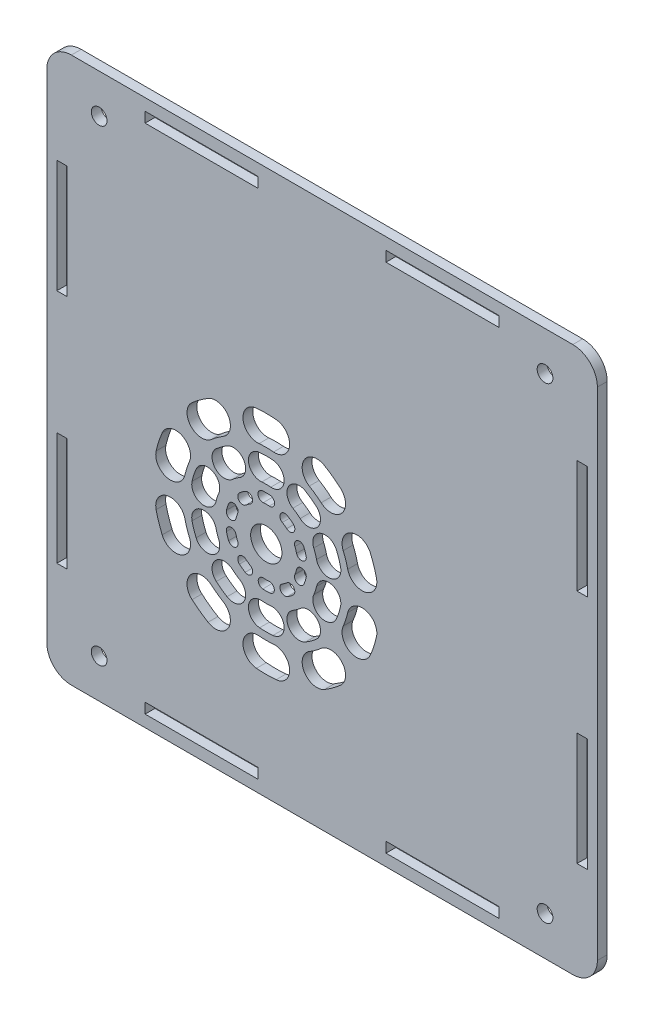
from build123d import *

# Parameters (mm, degrees)
SKETCH_1_W          = 112
SKETCH_1_H          = 111
EXTRUDE_1_DEPTH     = 2
SKETCH_2_R          = 1.6
CUT_EXTRUDE_1_DEPTH = 3
SKETCH_3_W          = 2.1
SKETCH_3_H          = 23
SKETCH_3_W_2        = 23
SKETCH_3_H_2        = 2.1
CUT_EXTRUDE_2_DEPTH = 3
SKETCH_4_R          = 3.180968653
CUT_EXTRUDE_4_DEPTH = 10
FILLET_1_R          = 5


with BuildPart() as part:
    # 草图1 → 凸台-拉伸1 (new body)
    with BuildSketch(Plane.XY):
        Rectangle(SKETCH_1_W, SKETCH_1_H)
    extrude(amount=EXTRUDE_1_DEPTH)

    # 草图2 → 切除-拉伸1 (cut, through all)
    with BuildSketch(Plane(origin=(0, 0, 0), x_dir=(-1, 0, 0), z_dir=(0, 0, -1))):
        with Locations((-45.35, -47.55)):
            Circle(SKETCH_2_R)
        with Locations((45.35, -47.55)):
            Circle(SKETCH_2_R)
        with Locations((45.35, 47.55)):
            Circle(SKETCH_2_R)
        with Locations((-45.35, 47.55)):
            Circle(SKETCH_2_R)
    extrude(amount=-CUT_EXTRUDE_1_DEPTH, mode=Mode.SUBTRACT)

    # 草图3 → 切除-拉伸2 (cut, through all)
    with BuildSketch(Plane(origin=(0, 0, 0), x_dir=(-1, 0, 0), z_dir=(0, 0, -1))):
        with Locations((-52.9, 24)):
            Rectangle(SKETCH_3_W, SKETCH_3_H)
        with Locations((-52.9, -24)):
            Rectangle(SKETCH_3_W, SKETCH_3_H)
        with Locations((52.9, -24)):
            Rectangle(SKETCH_3_W, SKETCH_3_H)
        with Locations((52.9, 24)):
            Rectangle(SKETCH_3_W, SKETCH_3_H)
        with Locations((-24.5, -52.05)):
            Rectangle(SKETCH_3_W_2, SKETCH_3_H_2)
        with Locations((24.5, -52.05)):
            Rectangle(SKETCH_3_W_2, SKETCH_3_H_2)
        with Locations((24.5, 52.05)):
            Rectangle(SKETCH_3_W_2, SKETCH_3_H_2)
        with Locations((-24.5, 52.05)):
            Rectangle(SKETCH_3_W_2, SKETCH_3_H_2)
    extrude(amount=-CUT_EXTRUDE_2_DEPTH, mode=Mode.SUBTRACT)

    # 草图4 → 切除-拉伸4 (cut)
    with BuildSketch(Plane.XY.offset(2)):
        with Locations((-11.35, -10.8)):
            Circle(SKETCH_4_R)
        with BuildLine():
            ThreePointArc((-9.345417917, 12.112478056), (-11.35, 12.2), (-13.354582083, 12.112478056))
            ThreePointArc((-13.354582083, 12.112478056), (-16.081698949, 8.862426734), (-12.831647627, 6.135309868))
            ThreePointArc((-12.831647627, 6.135309868), (-11.35, 6.2), (-9.868352373, 6.135309868))
            ThreePointArc((-9.868352373, 6.135309868), (-6.618301051, 8.862426734), (-9.345417917, 12.112478056))
        make_face()
        with BuildLine():
            ThreePointArc((-9.999085987, 4.64101782), (-11.35, 4.7), (-12.700914013, 4.64101782))
            ThreePointArc((-12.700914013, 4.64101782), (-14.973511401, 1.932641718), (-12.265135299, -0.33995567))
            ThreePointArc((-12.265135299, -0.33995567), (-11.35, -0.3), (-10.434864701, -0.33995567))
            ThreePointArc((-10.434864701, -0.33995567), (-7.726488599, 1.932641718), (-9.999085987, 4.64101782))
        make_face()
        with BuildLine():
            ThreePointArc((-10.565598315, -1.834247717), (-11.35, -1.8), (-12.134401685, -1.834247717))
            ThreePointArc((-12.134401685, -1.834247717), (-13.04344064, -2.917598158), (-11.960090199, -3.826637113))
            ThreePointArc((-11.960090199, -3.826637113), (-11.35, -3.8), (-10.739909801, -3.826637113))
            ThreePointArc((-10.739909801, -3.826637113), (-9.65655936, -2.917598158), (-10.565598315, -1.834247717))
        make_face()
        with BuildLine():
            ThreePointArc((3.739357667, 6.558320345), (2.169060803, 7.807390871), (0.495875723, 8.914847916))
            ThreePointArc((0.495875723, 8.914847916), (-3.620740404, 7.888460239), (-2.594352727, 3.771844112))
            ThreePointArc((-2.594352727, 3.771844112), (-1.357650711, 2.953288904), (-0.196996507, 2.030062864))
            ThreePointArc((-0.196996507, 2.030062864), (4.03530932, 2.326014517), (3.739357667, 6.558320345))
        make_face()
        with BuildLine():
            ThreePointArc((-1.181085051, 0.897998493), (-2.239328589, 1.739763413), (-3.366909839, 2.486093161))
            ThreePointArc((-3.366909839, 2.486093161), (-6.797423278, 1.630770096), (-5.942100213, -1.799743343))
            ThreePointArc((-5.942100213, -1.799743343), (-5.178254851, -2.305321559), (-4.461380196, -2.875549408))
            ThreePointArc((-4.461380196, -2.875549408), (-0.934458673, -2.62892303), (-1.181085051, 0.897998493))
        make_face()
        with BuildLine():
            ThreePointArc((-5.890850024, -4.519966337), (-6.458964736, -4.06806749), (-7.06430318, -3.667402714))
            ThreePointArc((-7.06430318, -3.667402714), (-8.436508555, -4.00953194), (-8.09437933, -5.381737316))
            ThreePointArc((-8.09437933, -5.381737316), (-7.63453524, -5.686101479), (-7.202968082, -6.029385497))
            ThreePointArc((-7.202968082, -6.029385497), (-5.792199472, -5.930734946), (-5.890850024, -4.519966337))
        make_face()
        with BuildLine():
            ThreePointArc((11.06051149, -5.62612575), (10.524299875, -3.692609129), (9.821611629, -1.813184045))
            ThreePointArc((9.821611629, -1.813184045), (5.887903684, -0.22386287), (4.298582509, -4.157570816))
            ThreePointArc((4.298582509, -4.157570816), (4.817960777, -5.546711096), (5.214291101, -6.975832076))
            ThreePointArc((5.214291101, -6.975832076), (8.812254459, -9.224089107), (11.06051149, -5.62612575))
        make_face()
        with BuildLine():
            ThreePointArc((3.752736004, -7.313258658), (3.391376003, -6.010236587), (2.917825229, -4.743667508))
            ThreePointArc((2.917825229, -4.743667508), (-0.360264726, -3.419233196), (-1.684699039, -6.697323151))
            ThreePointArc((-1.684699039, -6.697323151), (-1.363906579, -7.555321559), (-1.11911432, -8.438013929))
            ThreePointArc((-1.11911432, -8.438013929), (1.879188478, -10.311561455), (3.752736004, -7.313258658))
        make_face()
        with BuildLine():
            ThreePointArc((-3.242143723, -8.928153887), (-3.436138702, -8.228630591), (-3.690362945, -7.548676969))
            ThreePointArc((-3.690362945, -7.548676969), (-5.001598927, -7.018903244), (-5.531372652, -8.330139226))
            ThreePointArc((-5.531372652, -8.330139226), (-5.338251735, -8.84666458), (-5.190883853, -9.378055996))
            ThreePointArc((-5.190883853, -9.378055996), (-3.991562734, -10.127475007), (-3.242143723, -8.928153887))
        make_face()
        with BuildLine():
            ThreePointArc((9.821611629, -19.786815955), (10.524299875, -17.907390871), (11.06051149, -15.97387425))
            ThreePointArc((11.06051149, -15.97387425), (8.812254459, -12.375910893), (5.214291101, -14.624167924))
            ThreePointArc((5.214291101, -14.624167924), (4.817960777, -16.053288904), (4.298582509, -17.442429184))
            ThreePointArc((4.298582509, -17.442429184), (5.887903684, -21.37613713), (9.821611629, -19.786815955))
        make_face()
        with BuildLine():
            ThreePointArc((2.917825229, -16.856332492), (3.391376003, -15.589763413), (3.752736004, -14.286741342))
            ThreePointArc((3.752736004, -14.286741342), (1.879188478, -11.288438545), (-1.11911432, -13.161986071))
            ThreePointArc((-1.11911432, -13.161986071), (-1.363906579, -14.044678441), (-1.684699039, -14.902676849))
            ThreePointArc((-1.684699039, -14.902676849), (-0.360264726, -18.180766804), (2.917825229, -16.856332492))
        make_face()
        with BuildLine():
            ThreePointArc((-3.690362945, -14.051323031), (-3.436138702, -13.371369409), (-3.242143723, -12.671846113))
            ThreePointArc((-3.242143723, -12.671846113), (-3.991562734, -11.472524993), (-5.190883853, -12.221944004))
            ThreePointArc((-5.190883853, -12.221944004), (-5.338251735, -12.75333542), (-5.531372652, -13.269860774))
            ThreePointArc((-5.531372652, -13.269860774), (-5.001598927, -14.581096756), (-3.690362945, -14.051323031))
        make_face()
        with BuildLine():
            ThreePointArc((0.495875723, -30.514847916), (2.169060803, -29.407390871), (3.739357667, -28.158320345))
            ThreePointArc((3.739357667, -28.158320345), (4.03530932, -23.926014517), (-0.196996507, -23.630062864))
            ThreePointArc((-0.196996507, -23.630062864), (-1.357650711, -24.553288904), (-2.594352727, -25.371844112))
            ThreePointArc((-2.594352727, -25.371844112), (-3.620740404, -29.488460239), (0.495875723, -30.514847916))
        make_face()
        with BuildLine():
            ThreePointArc((-3.366909839, -24.086093161), (-2.239328589, -23.339763413), (-1.181085051, -22.497998493))
            ThreePointArc((-1.181085051, -22.497998493), (-0.934458673, -18.97107697), (-4.461380196, -18.724450592))
            ThreePointArc((-4.461380196, -18.724450592), (-5.178254851, -19.294678441), (-5.942100213, -19.800256657))
            ThreePointArc((-5.942100213, -19.800256657), (-6.797423278, -23.230770096), (-3.366909839, -24.086093161))
        make_face()
        with BuildLine():
            ThreePointArc((-7.06430318, -17.932597286), (-6.458964736, -17.53193251), (-5.890850024, -17.080033663))
            ThreePointArc((-5.890850024, -17.080033663), (-5.792199472, -15.669265054), (-7.202968082, -15.570614503))
            ThreePointArc((-7.202968082, -15.570614503), (-7.63453524, -15.913898521), (-8.09437933, -16.218262684))
            ThreePointArc((-8.09437933, -16.218262684), (-8.436508555, -17.59046806), (-7.06430318, -17.932597286))
        make_face()
        with BuildLine():
            ThreePointArc((-13.354582083, -33.712478056), (-11.35, -33.8), (-9.345417917, -33.712478056))
            ThreePointArc((-9.345417917, -33.712478056), (-6.618301051, -30.462426734), (-9.868352373, -27.735309868))
            ThreePointArc((-9.868352373, -27.735309868), (-11.35, -27.8), (-12.831647627, -27.735309868))
            ThreePointArc((-12.831647627, -27.735309868), (-16.081698949, -30.462426734), (-13.354582083, -33.712478056))
        make_face()
        with BuildLine():
            ThreePointArc((-12.700914013, -26.24101782), (-11.35, -26.3), (-9.999085987, -26.24101782))
            ThreePointArc((-9.999085987, -26.24101782), (-7.726488599, -23.532641718), (-10.434864701, -21.26004433))
            ThreePointArc((-10.434864701, -21.26004433), (-11.35, -21.3), (-12.265135299, -21.26004433))
            ThreePointArc((-12.265135299, -21.26004433), (-14.973511401, -23.532641718), (-12.700914013, -26.24101782))
        make_face()
        with BuildLine():
            ThreePointArc((-12.075233935, -19.089461805), (-11.35, -19.121126202), (-10.624766065, -19.089461805))
            ThreePointArc((-10.624766065, -19.089461805), (-9.71572711, -18.006111364), (-10.799077551, -17.097072409))
            ThreePointArc((-10.799077551, -17.097072409), (-11.35, -17.121126202), (-11.900922449, -17.097072409))
            ThreePointArc((-11.900922449, -17.097072409), (-12.98427289, -18.006111364), (-12.075233935, -19.089461805))
        make_face()
        with BuildLine():
            ThreePointArc((-26.439357667, -28.158320345), (-24.869060803, -29.407390871), (-23.195875723, -30.514847916))
            ThreePointArc((-23.195875723, -30.514847916), (-19.079259596, -29.488460239), (-20.105647273, -25.371844112))
            ThreePointArc((-20.105647273, -25.371844112), (-21.342349289, -24.553288904), (-22.503003493, -23.630062864))
            ThreePointArc((-22.503003493, -23.630062864), (-26.73530932, -23.926014517), (-26.439357667, -28.158320345))
        make_face()
        with BuildLine():
            ThreePointArc((-21.518914949, -22.497998493), (-20.460671411, -23.339763413), (-19.333090161, -24.086093161))
            ThreePointArc((-19.333090161, -24.086093161), (-15.902576722, -23.230770096), (-16.757899787, -19.800256657))
            ThreePointArc((-16.757899787, -19.800256657), (-17.521745149, -19.294678441), (-18.238619804, -18.724450592))
            ThreePointArc((-18.238619804, -18.724450592), (-21.765541327, -18.97107697), (-21.518914949, -22.497998493))
        make_face()
        with BuildLine():
            ThreePointArc((-16.809149976, -17.080033663), (-16.241035264, -17.53193251), (-15.63569682, -17.932597286))
            ThreePointArc((-15.63569682, -17.932597286), (-14.263491445, -17.59046806), (-14.60562067, -16.218262684))
            ThreePointArc((-14.60562067, -16.218262684), (-15.06546476, -15.913898521), (-15.497031918, -15.570614503))
            ThreePointArc((-15.497031918, -15.570614503), (-16.907800528, -15.669265054), (-16.809149976, -17.080033663))
        make_face()
        with BuildLine():
            ThreePointArc((-33.76051149, -15.97387425), (-33.224299875, -17.907390871), (-32.521611629, -19.786815955))
            ThreePointArc((-32.521611629, -19.786815955), (-28.587903684, -21.37613713), (-26.998582509, -17.442429184))
            ThreePointArc((-26.998582509, -17.442429184), (-27.517960777, -16.053288904), (-27.914291101, -14.624167924))
            ThreePointArc((-27.914291101, -14.624167924), (-31.512254459, -12.375910893), (-33.76051149, -15.97387425))
        make_face()
        with BuildLine():
            ThreePointArc((-26.452736004, -14.286741342), (-26.091376003, -15.589763413), (-25.617825229, -16.856332492))
            ThreePointArc((-25.617825229, -16.856332492), (-22.339735274, -18.180766804), (-21.015300961, -14.902676849))
            ThreePointArc((-21.015300961, -14.902676849), (-21.336093421, -14.044678441), (-21.58088568, -13.161986071))
            ThreePointArc((-21.58088568, -13.161986071), (-24.579188478, -11.288438545), (-26.452736004, -14.286741342))
        make_face()
        with BuildLine():
            ThreePointArc((-19.457856277, -12.671846113), (-19.263861298, -13.371369409), (-19.009637055, -14.051323031))
            ThreePointArc((-19.009637055, -14.051323031), (-17.698401073, -14.581096756), (-17.168627348, -13.269860774))
            ThreePointArc((-17.168627348, -13.269860774), (-17.361748265, -12.75333542), (-17.509116147, -12.221944004))
            ThreePointArc((-17.509116147, -12.221944004), (-18.708437266, -11.472524993), (-19.457856277, -12.671846113))
        make_face()
        with BuildLine():
            ThreePointArc((-32.521611629, -1.813184045), (-33.224299875, -3.692609129), (-33.76051149, -5.62612575))
            ThreePointArc((-33.76051149, -5.62612575), (-31.512254459, -9.224089107), (-27.914291101, -6.975832076))
            ThreePointArc((-27.914291101, -6.975832076), (-27.517960777, -5.546711096), (-26.998582509, -4.157570816))
            ThreePointArc((-26.998582509, -4.157570816), (-28.587903684, -0.22386287), (-32.521611629, -1.813184045))
        make_face()
        with BuildLine():
            ThreePointArc((-25.617825229, -4.743667508), (-26.091376003, -6.010236587), (-26.452736004, -7.313258658))
            ThreePointArc((-26.452736004, -7.313258658), (-24.579188478, -10.311561455), (-21.58088568, -8.438013929))
            ThreePointArc((-21.58088568, -8.438013929), (-21.336093421, -7.555321559), (-21.015300961, -6.697323151))
            ThreePointArc((-21.015300961, -6.697323151), (-22.339735274, -3.419233196), (-25.617825229, -4.743667508))
        make_face()
        with BuildLine():
            ThreePointArc((-19.009637055, -7.548676969), (-19.263861298, -8.228630591), (-19.457856277, -8.928153887))
            ThreePointArc((-19.457856277, -8.928153887), (-18.708437266, -10.127475007), (-17.509116147, -9.378055996))
            ThreePointArc((-17.509116147, -9.378055996), (-17.361748265, -8.84666458), (-17.168627348, -8.330139226))
            ThreePointArc((-17.168627348, -8.330139226), (-17.698401073, -7.018903244), (-19.009637055, -7.548676969))
        make_face()
        with BuildLine():
            ThreePointArc((-23.195875723, 8.914847916), (-24.869060803, 7.807390871), (-26.439357667, 6.558320345))
            ThreePointArc((-26.439357667, 6.558320345), (-26.73530932, 2.326014517), (-22.503003493, 2.030062864))
            ThreePointArc((-22.503003493, 2.030062864), (-21.342349289, 2.953288904), (-20.105647273, 3.771844112))
            ThreePointArc((-20.105647273, 3.771844112), (-19.079259596, 7.888460239), (-23.195875723, 8.914847916))
        make_face()
        with BuildLine():
            ThreePointArc((-19.333090161, 2.486093161), (-20.460671411, 1.739763413), (-21.518914949, 0.897998493))
            ThreePointArc((-21.518914949, 0.897998493), (-21.765541327, -2.62892303), (-18.238619804, -2.875549408))
            ThreePointArc((-18.238619804, -2.875549408), (-17.521745149, -2.305321559), (-16.757899787, -1.799743343))
            ThreePointArc((-16.757899787, -1.799743343), (-15.902576722, 1.630770096), (-19.333090161, 2.486093161))
        make_face()
        with BuildLine():
            ThreePointArc((-15.63569682, -3.667402714), (-16.241035264, -4.06806749), (-16.809149976, -4.519966337))
            ThreePointArc((-16.809149976, -4.519966337), (-16.907800528, -5.930734946), (-15.497031918, -6.029385497))
            ThreePointArc((-15.497031918, -6.029385497), (-15.06546476, -5.686101479), (-14.60562067, -5.381737316))
            ThreePointArc((-14.60562067, -5.381737316), (-14.263491445, -4.00953194), (-15.63569682, -3.667402714))
        make_face()
    extrude(amount=-CUT_EXTRUDE_4_DEPTH, mode=Mode.SUBTRACT)

    # 圆角1
    fillet_1_edges = [part.edges().sort_by_distance(p)[0] for p in [
        (56, -55.5, 1),
        (-56, -55.5, 1),
        (-56, 55.5, 1),
        (56, 55.5, 1),
    ]]
    fillet(fillet_1_edges, radius=FILLET_1_R)


solid = part.part
